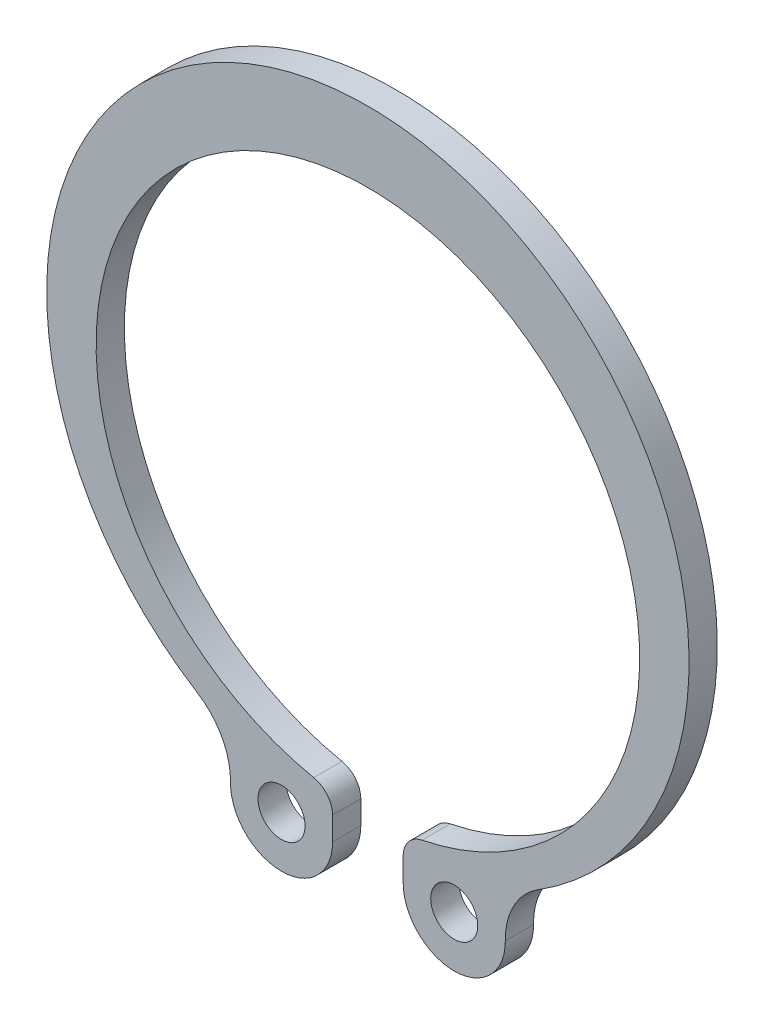
from build123d import *

# Parameters (mm, degrees)
SKETCH_1_R      = 1
EXTRUDE_1_DEPTH = 1.2


with BuildPart() as part:
    # Эскиз1 → Бобышка-Вытянуть1 (new body)
    with BuildSketch(Plane.XY):
        with BuildLine():
            Line((-1.5, -14.18300089), (-1.5, -13.198475515))
            ThreePointArc((-1.5, -13.198475515), (-1.725660544, -12.565705094), (-2.300796813, -12.218517307))
            ThreePointArc((-2.300796813, -12.218517307), (0, 10.65), (2.300796813, -12.218517307))
            ThreePointArc((2.300796813, -12.218517307), (1.725660544, -12.565705094), (1.5, -13.198475515))
            Line((1.5, -13.198475515), (1.5, -14.18300089))
            ThreePointArc((1.5, -14.18300089), (3.684691065, -16.352414157), (5.838719697, -14.152552883))
            ThreePointArc((5.838719697, -14.152552883), (6.203646888, -12.675893388), (7.245915351, -11.56802536))
            ThreePointArc((7.245915351, -11.56802536), (0, 13.65), (-7.245915351, -11.56802536))
            ThreePointArc((-7.245915351, -11.56802536), (-6.203646888, -12.675893388), (-5.838719697, -14.152552883))
            ThreePointArc((-5.838719697, -14.152552883), (-3.684691065, -16.352414157), (-1.5, -14.18300089))
        make_face()
        with Locations((-3.669466687, -14.18300089)):
            Circle(SKETCH_1_R, mode=Mode.SUBTRACT)
        with Locations((3.669466687, -14.18300089)):
            Circle(SKETCH_1_R, mode=Mode.SUBTRACT)
    extrude(amount=EXTRUDE_1_DEPTH)


solid = part.part
